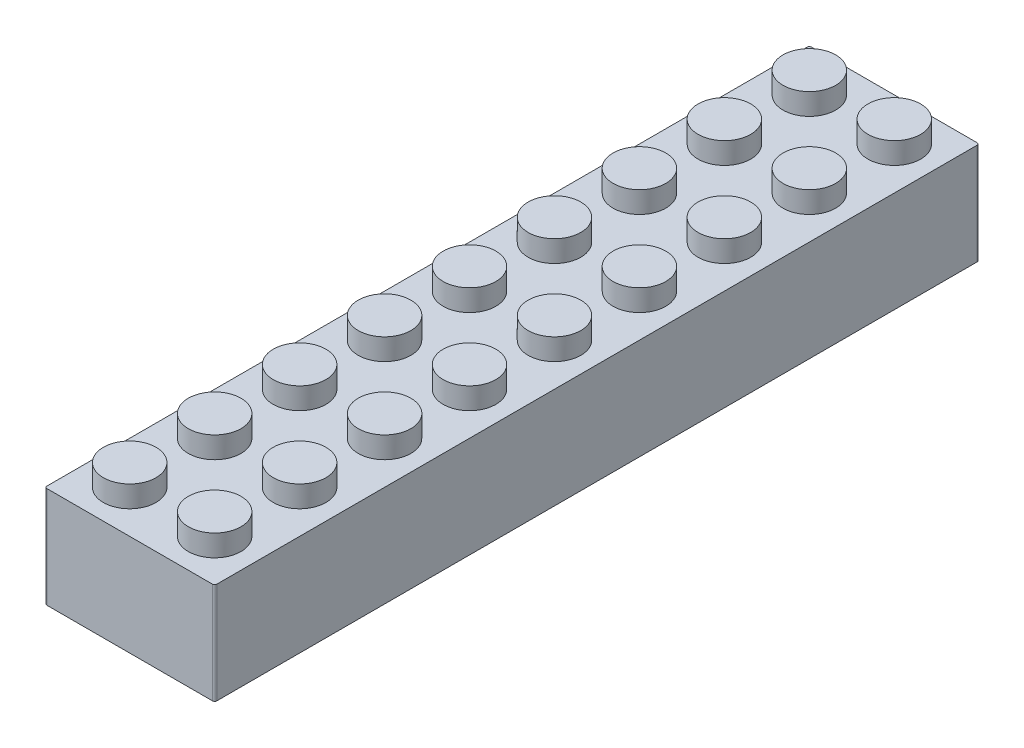
from build123d import *

# Parameters (mm, degrees)
SKETCH1_W           = 15.8
SKETCH1_H           = 71.1
BOSS_EXTRUDE1_DEPTH = 4.7
SKETCH2_R           = 2.45
BOSS_EXTRUDE2_DEPTH = 2
SKETCH3_W           = 12.9
SKETCH3_H           = 68.2
CUT_EXTRUDE1_DEPTH  = 4
SKETCH4_R           = 3.2
SKETCH4_R_2         = 2.4
BOSS_EXTRUDE3_DEPTH = 4
FILLET1_R           = 0.2


with BuildPart() as part:
    # Sketch1 → Boss-Extrude1 (new body, symmetric)
    with BuildSketch(Plane(origin=(0, 0, 0), x_dir=(1, 0, 0), z_dir=(0, 1, 0))):
        with Locations((7.9, 35.55)):
            Rectangle(SKETCH1_W, SKETCH1_H)
    extrude(amount=BOSS_EXTRUDE1_DEPTH, both=True)

    # Sketch2 → Boss-Extrude2 (add)
    with BuildSketch(Plane(origin=(0, 4.7, 0), x_dir=(1, 0, 0), z_dir=(0, 1, 0))):
        with Locations((3.95, 3.95)):
            Circle(SKETCH2_R)
        with Locations((11.85, 3.95)):
            Circle(SKETCH2_R)
        with Locations((11.85, 11.85)):
            Circle(SKETCH2_R)
        with Locations((3.95, 11.85)):
            Circle(SKETCH2_R)
        with Locations((3.95, 19.75)):
            Circle(SKETCH2_R)
        with Locations((3.95, 27.65)):
            Circle(SKETCH2_R)
        with Locations((11.85, 27.65)):
            Circle(SKETCH2_R)
        with Locations((11.85, 35.55)):
            Circle(SKETCH2_R)
        with Locations((3.95, 35.55)):
            Circle(SKETCH2_R)
        with Locations((3.95, 43.45)):
            Circle(SKETCH2_R)
        with Locations((11.85, 43.45)):
            Circle(SKETCH2_R)
        with Locations((3.95, 51.35)):
            Circle(SKETCH2_R)
        with Locations((11.85, 51.35)):
            Circle(SKETCH2_R)
        with Locations((3.95, 59.25)):
            Circle(SKETCH2_R)
        with Locations((11.85, 59.25)):
            Circle(SKETCH2_R)
        with Locations((3.95, 67.15)):
            Circle(SKETCH2_R)
        with Locations((11.85, 67.15)):
            Circle(SKETCH2_R)
        with Locations((11.85, 19.75)):
            Circle(SKETCH2_R)
    extrude(amount=BOSS_EXTRUDE2_DEPTH)

    # Sketch3 → Cut-Extrude1 (cut)
    with BuildSketch(Plane.XZ.offset(4.7)):
        with Locations((7.9, -35.55)):
            Rectangle(SKETCH3_W, SKETCH3_H)
    extrude(amount=-CUT_EXTRUDE1_DEPTH, mode=Mode.SUBTRACT)

    # Sketch4 → Boss-Extrude3 (add)
    with BuildSketch(Plane.XZ.offset(0.7)):
        with Locations((7.9, -63.2)):
            Circle(SKETCH4_R)
        with Locations((7.9, -63.2)):
            Circle(SKETCH4_R_2, mode=Mode.SUBTRACT)
        with Locations((7.9, -55.3)):
            Circle(SKETCH4_R)
        with Locations((7.9, -55.3)):
            Circle(SKETCH4_R_2, mode=Mode.SUBTRACT)
        with Locations((7.9, -47.4)):
            Circle(SKETCH4_R)
        with Locations((7.9, -47.4)):
            Circle(SKETCH4_R_2, mode=Mode.SUBTRACT)
        with Locations((7.9, -39.5)):
            Circle(SKETCH4_R)
        with Locations((7.9, -39.5)):
            Circle(SKETCH4_R_2, mode=Mode.SUBTRACT)
        with Locations((7.9, -31.6)):
            Circle(SKETCH4_R)
        with Locations((7.9, -31.6)):
            Circle(SKETCH4_R_2, mode=Mode.SUBTRACT)
        with Locations((7.9, -23.7)):
            Circle(SKETCH4_R)
        with Locations((7.9, -23.7)):
            Circle(SKETCH4_R_2, mode=Mode.SUBTRACT)
        with Locations((7.9, -15.8)):
            Circle(SKETCH4_R)
        with Locations((7.9, -15.8)):
            Circle(SKETCH4_R_2, mode=Mode.SUBTRACT)
        with Locations((7.9, -7.9)):
            Circle(SKETCH4_R)
        with Locations((7.9, -7.9)):
            Circle(SKETCH4_R_2, mode=Mode.SUBTRACT)
    extrude(amount=BOSS_EXTRUDE3_DEPTH)

    # Fillet1
    fillet1_edges = [part.edges().sort_by_distance(p)[0] for p in [
        (0, 0, -71.1),
        (15.8, 0, -71.1),
        (15.8, 0, 0),
        (0, 0, 0),
    ]]
    fillet(fillet1_edges, radius=FILLET1_R)


solid = part.part
